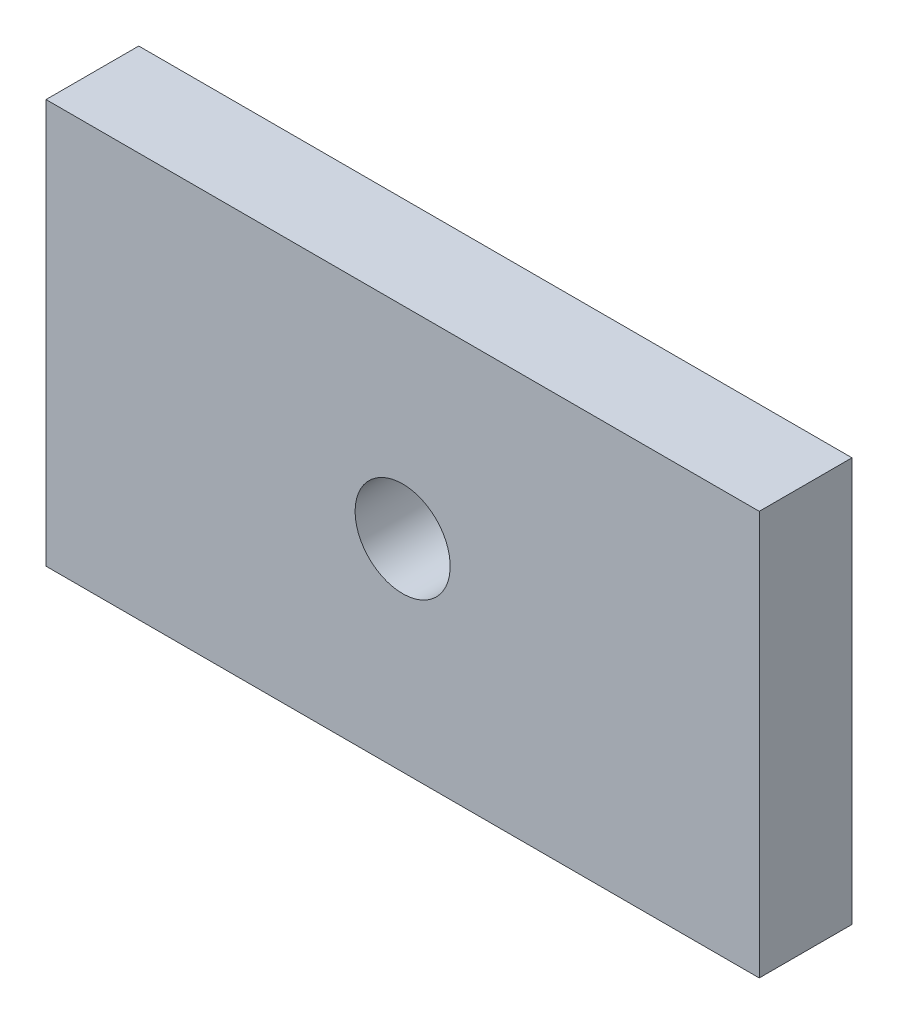
from build123d import *

# Parameters (mm, degrees)
ESQUISSE1_W                  = 30
ESQUISSE1_H                  = 17
BOSS_EXTRU_1_DEPTH           = 3.9
F_4_0_4_DIAMETER_HOLE1_D     = 4
F_4_0_4_DIAMETER_HOLE1_DEPTH = 3.9


with BuildPart() as part:
    # Esquisse1 → Boss.-Extru.1 (new body)
    with BuildSketch(Plane.XY):
        with Locations((0, 8.5)):
            Rectangle(ESQUISSE1_W, ESQUISSE1_H)
    extrude(amount=BOSS_EXTRU_1_DEPTH)

    # Ø4.0 (4) Diameter Hole1
    with Locations(Plane(origin=(0, 0, 0), x_dir=(-1, 0, 0), z_dir=(0, 0, -1))):
        with Locations((0, 8.5)):
            Hole(F_4_0_4_DIAMETER_HOLE1_D / 2, depth=F_4_0_4_DIAMETER_HOLE1_DEPTH)


solid = part.part
